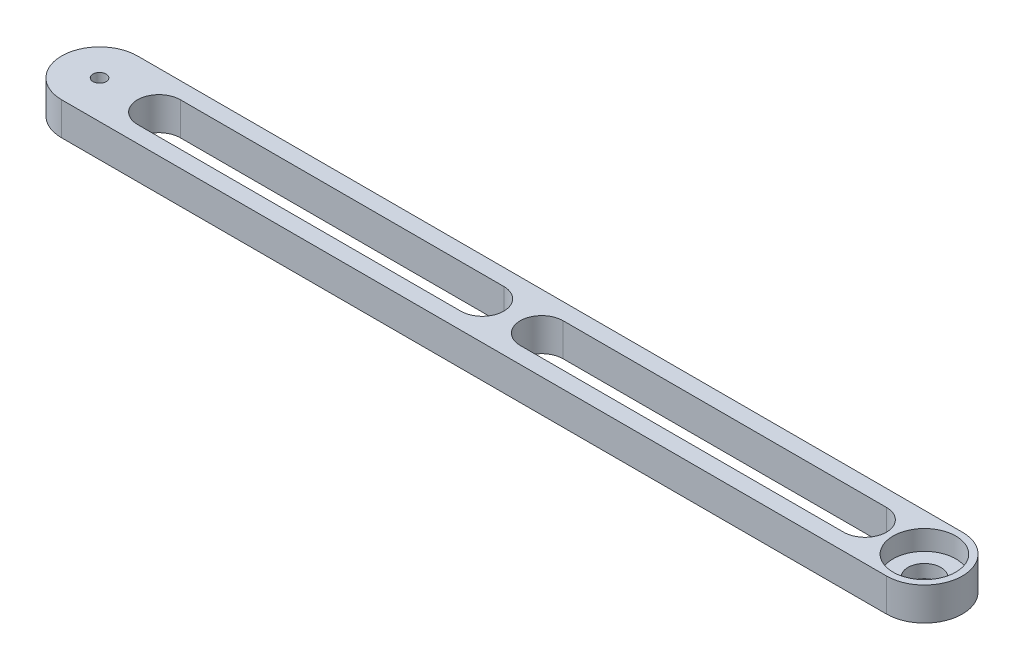
from build123d import *

# Parameters (mm, degrees)
SKETCH1_R           = 2
BOSS_EXTRUDE1_DEPTH = 10
SKETCH2_R           = 9.5
CUT_EXTRUDE1_DEPTH  = 6
SKETCH3_R           = 5
CUT_EXTRUDE2_DEPTH  = 11
CUT_EXTRUDE3_DEPTH  = 11


with BuildPart() as part:
    # Sketch1 → Boss-Extrude1 (new body)
    with BuildSketch(Plane(origin=(0, 0, 0), x_dir=(1, 0, 0), z_dir=(0, 1, 0))):
        with BuildLine():
            Line((0, 11.5), (250, 11.5))
            ThreePointArc((250, 11.5), (261.5, 0), (250, -11.5))
            Line((250, -11.5), (0, -11.5))
            ThreePointArc((0, -11.5), (-11.5, 0), (0, 11.5))
        make_face()
        Circle(SKETCH1_R, mode=Mode.SUBTRACT)
    extrude(amount=BOSS_EXTRUDE1_DEPTH)

    # Sketch2 → Cut-Extrude1 (cut)
    with BuildSketch(Plane(origin=(0, 10, 0), x_dir=(1, 0, 0), z_dir=(0, 1, 0))):
        with Locations((250, 0)):
            Circle(SKETCH2_R)
    extrude(amount=-CUT_EXTRUDE1_DEPTH, mode=Mode.SUBTRACT)

    # Sketch3 → Cut-Extrude2 (cut, through all)
    with BuildSketch(Plane(origin=(0, 0, 0), x_dir=(-1, 0, 0), z_dir=(0, -1, 0))):
        with Locations((-250, 0)):
            Circle(SKETCH3_R)
    extrude(amount=-CUT_EXTRUDE2_DEPTH, mode=Mode.SUBTRACT)

    # Sketch4 → Cut-Extrude3 (cut, through all)
    with BuildSketch(Plane(origin=(0, 10, 0), x_dir=(1, 0, 0), z_dir=(0, 1, 0))):
        with BuildLine():
            Line((18, 6.5), (116, 6.5))
            ThreePointArc((116, 6.5), (122.5, 0), (116, -6.5))
            Line((116, -6.5), (18, -6.5))
            ThreePointArc((18, -6.5), (11.5, 0), (18, 6.5))
        make_face()
        with BuildLine():
            Line((134, 6.5), (232, 6.5))
            ThreePointArc((232, 6.5), (238.5, 0), (232, -6.5))
            Line((232, -6.5), (134, -6.5))
            ThreePointArc((134, -6.5), (127.5, 0), (134, 6.5))
        make_face()
    extrude(amount=-CUT_EXTRUDE3_DEPTH, mode=Mode.SUBTRACT)


solid = part.part
